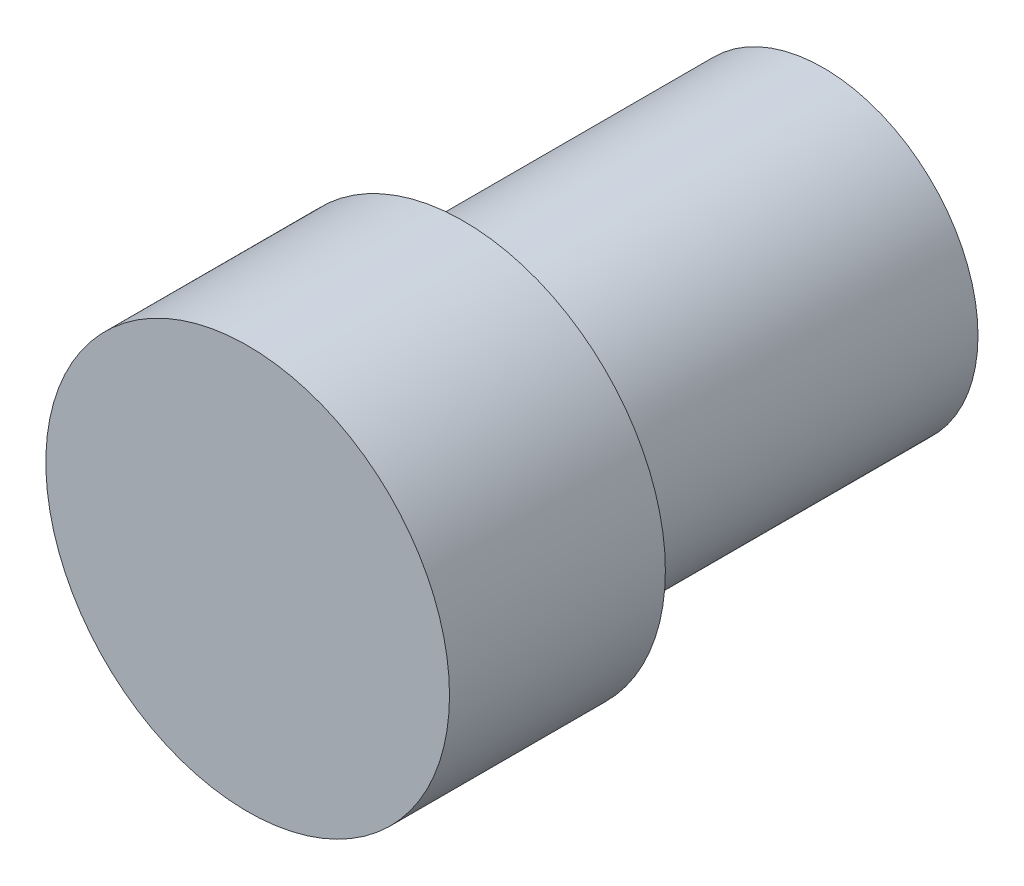
from build123d import *

# Parameters (mm, degrees)
SKETCH1_R      = 5.461
EXTRUDE1_DEPTH = 12.7
SKETCH2_R      = 7.125092069
EXTRUDE2_DEPTH = 7.62


with BuildPart() as part:
    # Sketch1 → Extrude1 (new body)
    with BuildSketch(Plane.XY):
        Circle(SKETCH1_R)
    extrude(amount=EXTRUDE1_DEPTH)

    # Sketch2 → Extrude2 (add)
    with BuildSketch(Plane.XY.offset(12.7)):
        Circle(SKETCH2_R)
    extrude(amount=EXTRUDE2_DEPTH)


solid = part.part
